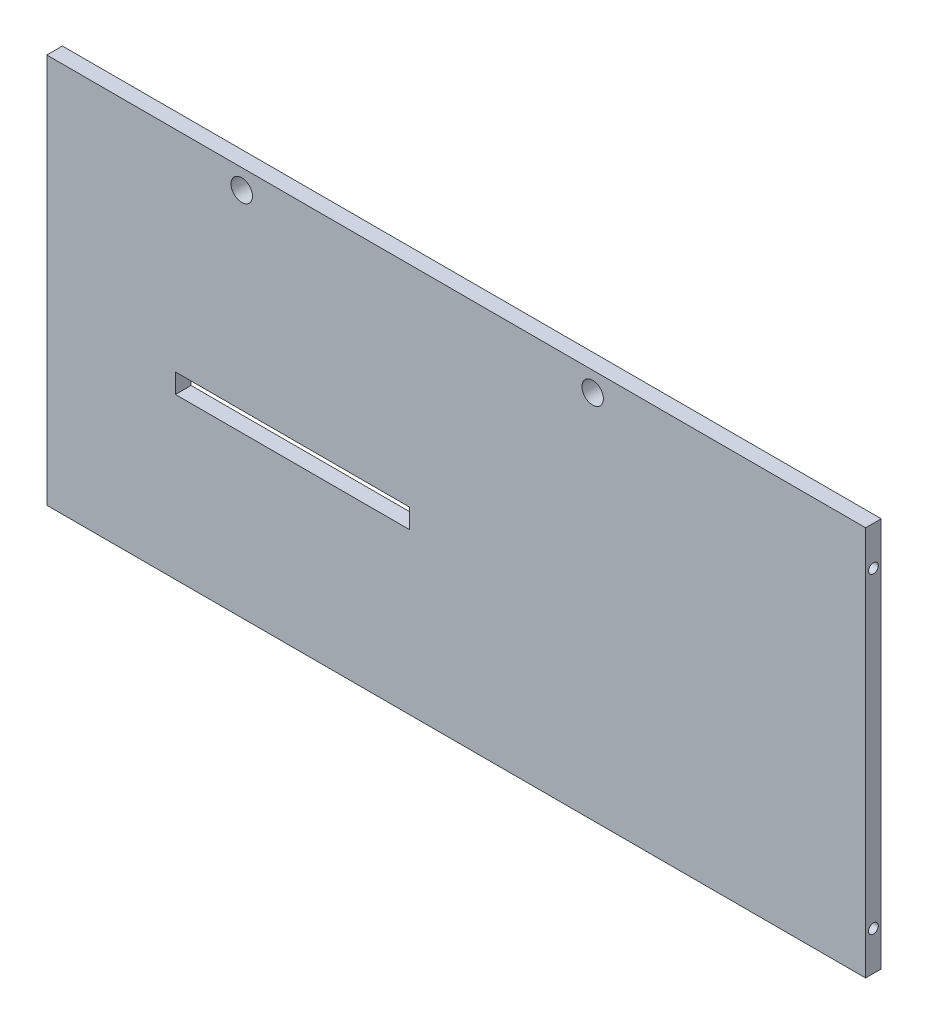
from build123d import *

# Parameters (mm, degrees)
SKETCH_1_W             = 200
SKETCH_1_H             = 100
EXTRUDE_1_DEPTH        = 4
SKETCH_5_R             = 2.75
CUT_EXTRUDE_1_DEPTH    = 5
SKETCH_6_W             = 4
SKETCH_6_H             = 100
EXTRUDE_2_DEPTH        = 10
SKETCH_7_W             = 60
SKETCH_7_H             = 5
CUT_EXTRUDE_2_DEPTH    = 5
HOLE_WIZARD_M3_1_D     = 2.5
HOLE_WIZARD_M3_1_DEPTH = 7.5
HOLE_WIZARD_M3_1_TIP   = 0.751075774
HOLE_WIZARD_M3_2_D     = 2.5
HOLE_WIZARD_M3_2_DEPTH = 7.5
HOLE_WIZARD_M3_2_TIP   = 0.751075774
HOLE_WIZARD_M3_3_D     = 2.5
HOLE_WIZARD_M3_3_DEPTH = 7.5
HOLE_WIZARD_M3_3_TIP   = 0.751075774


with BuildPart() as part:
    # 草图1 → 凸台-拉伸1 (new body)
    with BuildSketch(Plane.XY):
        with Locations((100, 50)):
            Rectangle(SKETCH_1_W, SKETCH_1_H)
    extrude(amount=EXTRUDE_1_DEPTH)

    # 草图5 → 切除-拉伸1 (cut, through all)
    with BuildSketch(Plane(origin=(0, 0, 0), x_dir=(-1, 0, 0), z_dir=(0, 0, -1))):
        with Locations((-50, 95)):
            Circle(SKETCH_5_R)
        with Locations((-140, 95)):
            Circle(SKETCH_5_R)
    extrude(amount=-CUT_EXTRUDE_1_DEPTH, mode=Mode.SUBTRACT)

    # 草图6 → 凸台-拉伸2 (add)
    with BuildSketch(Plane(origin=(200, 0, 0), x_dir=(0, 0, -1), z_dir=(1, 0, 0))):
        with Locations((-2, 50)):
            Rectangle(SKETCH_6_W, SKETCH_6_H)
    extrude(amount=EXTRUDE_2_DEPTH)

    # 草图7 → 切除-拉伸2 (cut)
    with BuildSketch(Plane(origin=(0, 0, 0), x_dir=(-1, 0, 0), z_dir=(0, 0, -1))):
        with Locations((-63, 43.6)):
            Rectangle(SKETCH_7_W, SKETCH_7_H)
    extrude(amount=-CUT_EXTRUDE_2_DEPTH, mode=Mode.SUBTRACT)

    # M3 螺纹孔1
    with Locations(Plane.ZY):
        with Locations((2, 10), (2, 90)):
            Hole(HOLE_WIZARD_M3_1_D / 2, depth=HOLE_WIZARD_M3_1_DEPTH)
            with Locations((0, 0, -(HOLE_WIZARD_M3_1_DEPTH + HOLE_WIZARD_M3_1_TIP / 2))):  # 118° drill point
                Cone(0, HOLE_WIZARD_M3_1_D / 2, HOLE_WIZARD_M3_1_TIP, mode=Mode.SUBTRACT)

    # M3 螺纹孔2
    with Locations(Plane(origin=(210, 0, 0), x_dir=(0, 0, -1), z_dir=(1, 0, 0))):
        with Locations((-2, 10), (-2, 90)):
            Hole(HOLE_WIZARD_M3_2_D / 2, depth=HOLE_WIZARD_M3_2_DEPTH)
            with Locations((0, 0, -(HOLE_WIZARD_M3_2_DEPTH + HOLE_WIZARD_M3_2_TIP / 2))):  # 118° drill point
                Cone(0, HOLE_WIZARD_M3_2_D / 2, HOLE_WIZARD_M3_2_TIP, mode=Mode.SUBTRACT)

    # M3 螺纹孔3
    with Locations(Plane(origin=(0, 0, 0), x_dir=(-1, 0, 0), z_dir=(0, -1, 0))):
        with Locations((-20, -2), (-190, -2)):
            Hole(HOLE_WIZARD_M3_3_D / 2, depth=HOLE_WIZARD_M3_3_DEPTH)
            with Locations((0, 0, -(HOLE_WIZARD_M3_3_DEPTH + HOLE_WIZARD_M3_3_TIP / 2))):  # 118° drill point
                Cone(0, HOLE_WIZARD_M3_3_D / 2, HOLE_WIZARD_M3_3_TIP, mode=Mode.SUBTRACT)


solid = part.part
